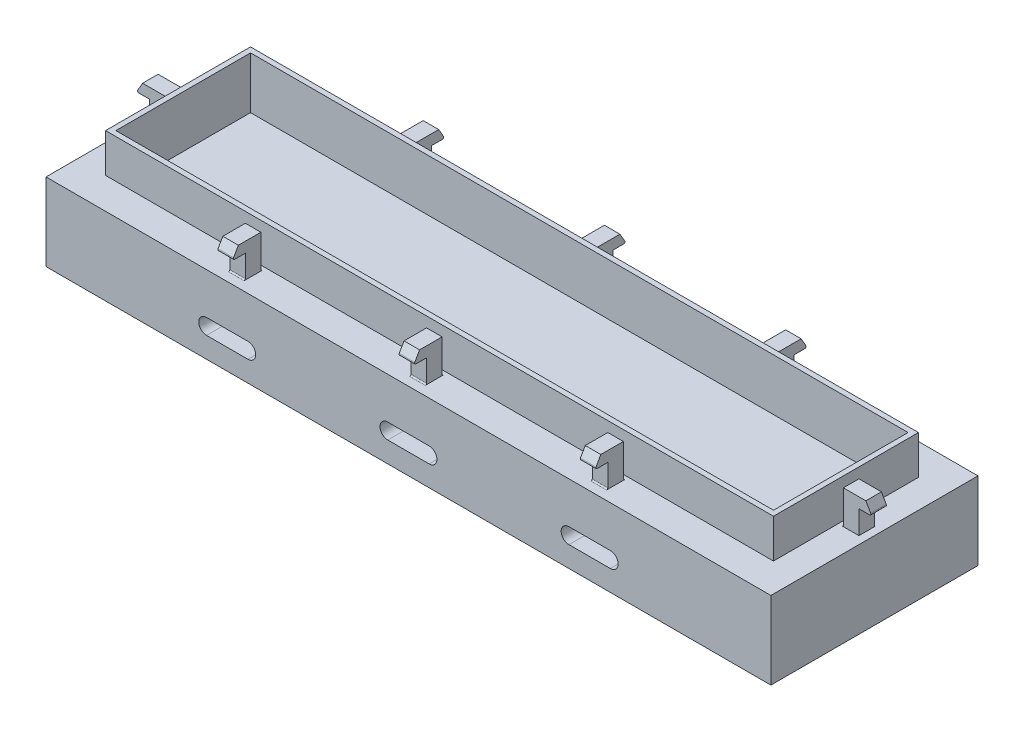
from build123d import *

# Parameters (mm, degrees)
SKETCH1_W             = 140
SKETCH1_H             = 40
BOSS_EXTRUDE1_DEPTH   = 15
BOSS_EXTRUDE2_DEPTH   = 1.5
BOSS_EXTRUDE3_DEPTH   = 1.5
BOSS_EXTRUDE4_DEPTH   = 1.5
FILLET2_R             = 0.25
MIRROR10_COPY_1_DEPTH = 1.5
MIRROR11_COPY_1_DEPTH = 1.5
MIRROR11_COPY_2_DEPTH = 1.5
MIRROR11_COPY_3_DEPTH = 1.5
MIRROR11_COPY_4_DEPTH = 1.5
SKETCH2_W             = 129
SKETCH2_H             = 28
BOSS_EXTRUDE5_DEPTH   = 7.5
SKETCH8_W             = 127
SKETCH8_H             = 26
CUT_EXTRUDE1_DEPTH    = 10
CUT_EXTRUDE2_DEPTH    = 41.5
CUT_EXTRUDE3_DEPTH    = 41.5
FILLET3_R             = 0.25
FILLET4_R             = 0.25


with BuildPart() as part:
    # Sketch1 → Boss-Extrude1 (new body)
    with BuildSketch(Plane(origin=(0, 0, 0), x_dir=(1, 0, 0), z_dir=(0, 1, 0))):
        Rectangle(SKETCH1_W, SKETCH1_H)
    extrude(amount=BOSS_EXTRUDE1_DEPTH)

    # Sketch3 → Boss-Extrude2 (add, symmetric)
    with BuildSketch(Plane.XY):
        Polygon((-65.5, 15), (-65.5, 21.5), (-69.845299462, 21.5), (-71, 19.5), (-68.5, 19.5), (-68.5, 15), align=None)
    boss_extrude2 = extrude(amount=BOSS_EXTRUDE2_DEPTH, both=True)

    # Sketch6 → Boss-Extrude3 (add)
    with BuildSketch(Plane(origin=(0, 0, 0), x_dir=(0, 0, -1), z_dir=(1, 0, 0))):
        Polygon((-15, 15), (-15, 21.5), (-19.345299462, 21.5), (-20.5, 19.5), (-18, 19.5), (-18, 15), align=None)
    boss_extrude3 = extrude(amount=-BOSS_EXTRUDE3_DEPTH)

    # Sketch7 → Boss-Extrude4 (add, symmetric)
    with BuildSketch(Plane(origin=(-35, 0, 0), x_dir=(0, 0, -1), z_dir=(1, 0, 0))):
        Polygon((-15, 15), (-15, 21.5), (-19.345299462, 21.5), (-20.5, 19.5), (-18, 19.5), (-18, 15), align=None)
    boss_extrude4 = extrude(amount=BOSS_EXTRUDE4_DEPTH, both=True)

    # Fillet2
    fillet2_edges = [part.edges().sort_by_distance(p)[0] for p in [
        (-71, 19.5, 0),
    ]]
    fillet(fillet2_edges, radius=FILLET2_R)

    # Mirror9: Boss-Extrude3 across plane
    add(boss_extrude3.mirror(Plane(origin=(0, 0, 0), x_dir=(0, 0, 1), z_dir=(1, 0, 0))))

    # Mirror10: Boss-Extrude4, Boss-Extrude3 across plane
    add(boss_extrude4.mirror(Plane.XY))
    add(boss_extrude3.mirror(Plane.XY))

    # Mirror10 copy 1 sketch → Mirror10 copy 1 (add)
    with BuildSketch(Plane.ZY):
        Polygon((-15, 15), (-15, 21.5), (-19.345299462, 21.5), (-20.5, 19.5), (-18, 19.5), (-18, 15), align=None)
    extrude(amount=-MIRROR10_COPY_1_DEPTH)

    # Mirror11: Boss-Extrude2, Boss-Extrude4 across plane
    add(boss_extrude2.mirror(Plane(origin=(0, 0, 0), x_dir=(0, 0, 1), z_dir=(1, 0, 0))))
    add(boss_extrude4.mirror(Plane(origin=(0, 0, 0), x_dir=(0, 0, 1), z_dir=(1, 0, 0))))

    # Mirror11 copy 1 sketch → Mirror11 copy 1 (add, symmetric)
    with BuildSketch(Plane.ZY.offset(-35)):
        Polygon((-15, 15), (-15, 21.5), (-19.345299462, 21.5), (-20.5, 19.5), (-18, 19.5), (-18, 15), align=None)
    extrude(amount=MIRROR11_COPY_1_DEPTH, both=True)

    # Mirror11 copy 2 sketch → Mirror11 copy 2 (add)
    with BuildSketch(Plane.ZY):
        Polygon((-15, 15), (-15, 21.5), (-19.345299462, 21.5), (-20.5, 19.5), (-18, 19.5), (-18, 15), align=None)
    extrude(amount=-MIRROR11_COPY_2_DEPTH)

    # Mirror11 copy 3 sketch → Mirror11 copy 3 (add)
    with BuildSketch(Plane(origin=(0, 0, 0), x_dir=(0, 0, 1), z_dir=(1, 0, 0))):
        Polygon((-15, -15), (-15, -21.5), (-19.345299462, -21.5), (-20.5, -19.5), (-18, -19.5), (-18, -15), align=None)
    extrude(amount=-MIRROR11_COPY_3_DEPTH)

    # Mirror11 copy 4 sketch → Mirror11 copy 4 (add)
    with BuildSketch(Plane(origin=(0, 0, 0), x_dir=(0, 0, -1), z_dir=(-1, 0, 0))):
        Polygon((-15, -15), (-15, -21.5), (-19.345299462, -21.5), (-20.5, -19.5), (-18, -19.5), (-18, -15), align=None)
    extrude(amount=-MIRROR11_COPY_4_DEPTH)

    # Sketch2 → Boss-Extrude5 (add)
    with BuildSketch(Plane(origin=(0, 15, 0), x_dir=(1, 0, 0), z_dir=(0, 1, 0))):
        Rectangle(SKETCH2_W, SKETCH2_H)
    extrude(amount=BOSS_EXTRUDE5_DEPTH)

    # Sketch8 → Cut-Extrude1 (cut)
    with BuildSketch(Plane(origin=(0, 22.5, 0), x_dir=(1, 0, 0), z_dir=(0, 1, 0))):
        Rectangle(SKETCH8_W, SKETCH8_H)
    extrude(amount=-CUT_EXTRUDE1_DEPTH, mode=Mode.SUBTRACT)

    # Sketch9 → Cut-Extrude2 (cut, through all)
    with BuildSketch(Plane.XY.offset(20)):
        with BuildLine():
            Line((-4, 7), (4, 7))
            ThreePointArc((4, 7), (5.5, 5.5), (4, 4))
            Line((4, 4), (-4, 4))
            ThreePointArc((-4, 4), (-5.5, 5.5), (-4, 7))
        make_face()
    extrude(amount=-CUT_EXTRUDE2_DEPTH, mode=Mode.SUBTRACT)

    # Sketch10 → Cut-Extrude3 (cut, through all)
    with BuildSketch(Plane.XY.offset(20)):
        with BuildLine():
            Line((-39, 7), (-31, 7))
            ThreePointArc((-31, 7), (-29.5, 5.5), (-31, 4))
            Line((-31, 4), (-39, 4))
            ThreePointArc((-39, 4), (-40.5, 5.5), (-39, 7))
        make_face()
    cut_extrude3 = extrude(amount=-CUT_EXTRUDE3_DEPTH, mode=Mode.SUBTRACT)

    # Mirror12: Cut-Extrude3 across plane
    add(cut_extrude3.mirror(Plane(origin=(0, 0, 0), x_dir=(0, 0, 1), z_dir=(1, 0, 0))), mode=Mode.SUBTRACT)

    # Fillet3
    fillet3_edges = [part.edges().sort_by_distance(p)[0] for p in [
        (0, 19.5, -20.5),
        (71, 19.5, 0),
        (35, 19.5, -20.5),
        (35, 19.5, 20.5),
        (0, 19.5, 20.5),
        (-35, 19.5, 20.5),
        (-35, 19.5, -20.5),
    ]]
    fillet(fillet3_edges, radius=FILLET3_R)

    # Fillet4
    fillet4_edges = [part.edges().sort_by_distance(p)[0] for p in [
        (0, 15, -15),
        (0, 15, -18),
        (65.5, 15, 0),
        (35, 15, -15),
        (35, 15, -18),
        (-65.5, 15, 0),
        (-68.5, 15, 0),
        (35, 15, 18),
        (35, 15, 15),
        (0, 15, 15),
        (0, 15, 18),
        (-35, 15, 15),
        (-35, 15, 18),
        (-35, 15, -18),
        (-35, 15, -15),
    ]]
    fillet(fillet4_edges, radius=FILLET4_R)


solid = part.part
